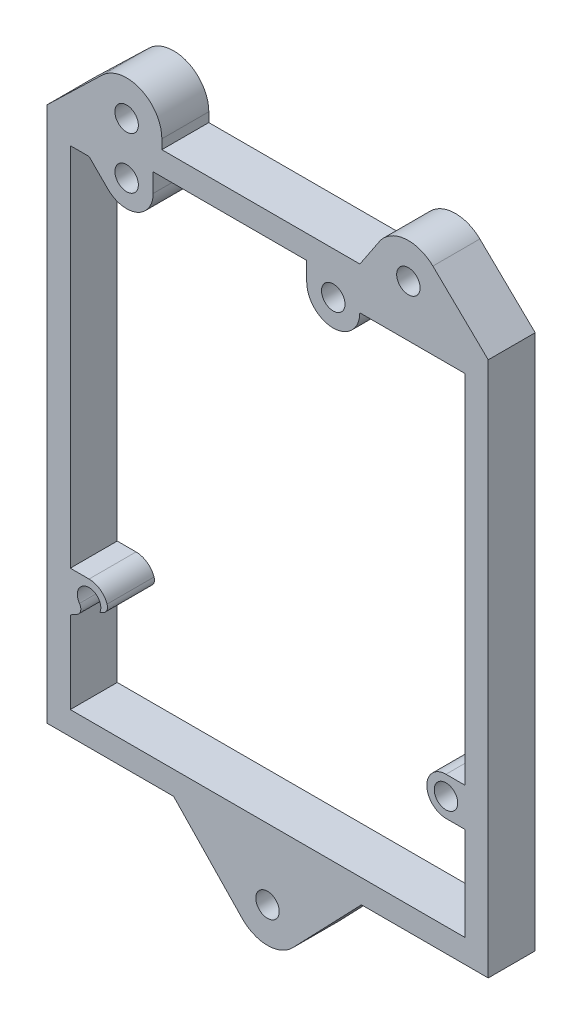
from build123d import *

# Parameters (mm, degrees)
SKETCH1_R           = 1.5875
BOSS_EXTRUDE1_DEPTH = 6.35
FILLET1_R           = 1


with BuildPart() as part:
    # Sketch1 → Boss-Extrude1 (new body)
    with BuildSketch(Plane.XY):
        with BuildLine():
            Line((13.97, -3.175), (23.234773085, -12.823578829))
            ThreePointArc((23.234773085, -12.823578829), (26.67, -14.2875), (30.105226915, -12.823578829))
            Line((30.105226915, -12.823578829), (39.37, -3.175))
            Line((39.37, -3.175), (56.515, -3.175))
            Line((56.515, -3.175), (56.515, 69.215))
            Line((56.515, 69.215), (49.029740814, 76.449473973))
            ThreePointArc((49.029740814, 76.449473973), (45.054787809, 77.740813715), (41.592139899, 75.400326764))
            Line((41.592139899, 75.400326764), (39.161128061, 71.755))
            Line((39.161128061, 71.755), (12.3825, 71.755))
            Line((12.3825, 71.755), (12.3825, 73.025))
            ThreePointArc((12.3825, 73.025), (9.479941615, 77.409292809), (4.310259186, 76.449473973))
            Line((4.310259186, 76.449473973), (-3.175, 69.215))
            Line((-3.175, 69.215), (-3.175, -3.175))
            Line((-3.175, -3.175), (13.97, -3.175))
        make_face()
        with Locations((35.56, 66.04)):
            Circle(SKETCH1_R, mode=Mode.SUBTRACT)
        with Locations((7.62, 66.04)):
            Circle(SKETCH1_R, mode=Mode.SUBTRACT)
        with Locations((50.8, 15.24)):
            Circle(SKETCH1_R, mode=Mode.SUBTRACT)
        with Locations((26.67, -9.525)):
            Circle(SKETCH1_R, mode=Mode.SUBTRACT)
        with Locations((45.72, 73.025)):
            Circle(SKETCH1_R, mode=Mode.SUBTRACT)
        with Locations((7.62, 73.025)):
            Circle(SKETCH1_R, mode=Mode.SUBTRACT)
        with BuildLine():
            Line((53.34, 66.04), (53.34, 17.8275))
            Line((53.34, 17.8275), (50.8, 17.8275))
            ThreePointArc((50.8, 17.8275), (48.2125, 15.24), (50.8, 12.6525))
            Line((50.8, 12.6525), (53.34, 12.6525))
            Line((53.34, 12.6525), (53.34, 0))
            Line((53.34, 0), (0, 0))
            Line((0, 0), (0, 11.093834149))
            Line((0, 11.093834149), (2.323755448, 12.397297058))
            ThreePointArc((2.323755448, 12.397297058), (1.763362672, 15.354554336), (3.994811275, 13.334641515))
            Line((3.994811275, 13.334641515), (5.1275, 13.97))
            ThreePointArc((5.1275, 13.97), (4.369638796, 15.799638796), (2.54, 16.5575))
            Line((2.54, 16.5575), (0, 16.5575))
            Line((0, 16.5575), (0, 66.04))
            Line((0, 66.04), (2.54, 66.04))
            Line((2.54, 66.04), (5.08, 63.506513025))
            ThreePointArc((5.08, 63.506513025), (8.990749111, 62.724701654), (11.2075, 66.04))
            Line((11.2075, 66.04), (11.2075, 68.58))
            Line((11.2075, 68.58), (31.9725, 68.58))
            Line((31.9725, 68.58), (31.9725, 66.04))
            ThreePointArc((31.9725, 66.04), (35.56, 62.4525), (39.1475, 66.04))
            Line((39.1475, 66.04), (40.386, 66.04))
            Line((40.386, 66.04), (53.34, 66.04))
        make_face(mode=Mode.SUBTRACT)
    extrude(amount=BOSS_EXTRUDE1_DEPTH)

    # Fillet1
    fillet1_edges = [part.edges().sort_by_distance(p)[0] for p in [
        (5.1275, 13.97, 3.175),
        (2.323755448, 12.397297058, 3.175),
    ]]
    fillet(fillet1_edges, radius=FILLET1_R)


solid = part.part
